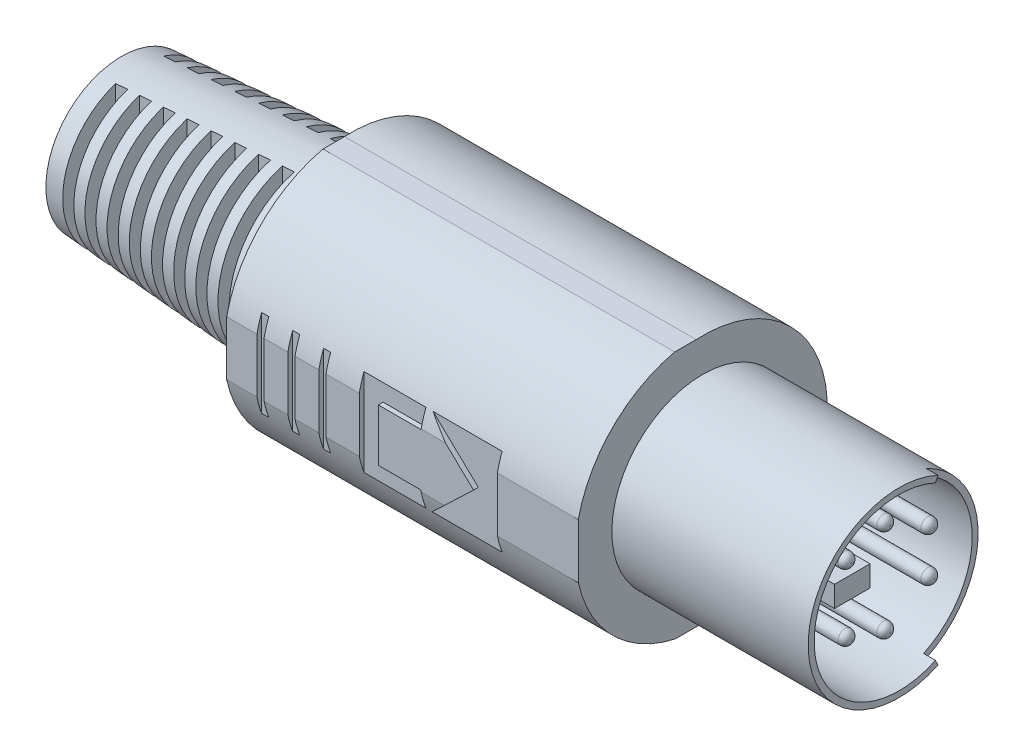
from build123d import *

# Parameters (mm, degrees)
SKETCH2_R                = 2.4384
BOSS_EXTRUDE_CABLE_DEPTH = 0.127
SKETCH13_R               = 4.87045
SKETCH12_R               = 4.03225
BODY_DEPTH               = 23.3299
SKETCH21_W               = 0.635
SKETCH21_H               = 5.3721
RIGID_CUTS_DEPTH         = 7.6421
RIGID_CUTS_DEPTH_BACK    = 7.6421
SKETCH16_R               = 4.8514
BOSS_EXTRUDE10_DEPTH     = 5.9
SKETCH17_R               = 4.5339
CUT_EXTRUDE4_DEPTH       = 0.8509
SKETCH18_R               = 4.5339
SKETCH18_R_2             = 0.381
SKETCH18_W               = 0.762
SKETCH18_H               = 2.1463
CUT_EXTRUDE5_DEPTH       = 12.7
SKETCH28_W               = 7.366
SKETCH28_H               = 6.858
SKETCH28_W_2             = 0.381
CUT_EXTRUDE7_DEPTH       = 0.254
SKETCH30_R               = 2.4384
SKETCH31_W               = 239.674694706
SKETCH31_H               = 23.82872503
CUT_EXTRUDE8_DEPTH       = 14.2842
FILLET1_R                = 0.3429
CUT_EXTRUDE9_DEPTH       = 0.635
SKETCH37_R               = 4.8514
CUT_EXTRUDE10_DEPTH      = 4.572
SKETCH39_R               = 16.8
SKETCH39_R_2             = 6.8
CUT_EXTRUDE_THIN1_DEPTH  = 19
SKETCH40_W               = 0.762
SKETCH40_H               = 2.1463
CUT_EXTRUDE11_DEPTH      = 12.7
SKETCH41_R               = 0.381
CUT_EXTRUDE12_DEPTH      = 13.5509
SKETCH42_W               = 1.897262774
SKETCH42_H               = 1.120293518
BOSS_EXTRUDE11_DEPTH     = 12


with BuildPart() as part:
    # Sketch2 → Boss-Extrude cable (new body, symmetric)
    with BuildSketch(Plane(origin=(0, 0, 0), x_dir=(0, 0, -1), z_dir=(1, 0, 0))):
        Circle(SKETCH2_R)
    extrude(amount=BOSS_EXTRUDE_CABLE_DEPTH, both=True)

    # Sketch13 → Rigid Back section 0
    with BuildSketch(Plane(origin=(12.3825, 0, 0), x_dir=(0, 0, -1), z_dir=(1, 0, 0))):
        Circle(SKETCH13_R)
    # Sketch12 → Rigid Back section 1
    with BuildSketch(Plane(origin=(0.127, 0, 0), x_dir=(0, 0, -1), z_dir=(1, 0, 0))):
        Circle(SKETCH12_R)
    loft()

    # Sketch14 → Body (add)
    with BuildSketch(Plane(origin=(12.3825, 0, 0), x_dir=(0, 0, -1), z_dir=(1, 0, 0))):
        with BuildLine():
            Line((-0.35513361, 6.632599229), (-6.6421, 6.632599229))
            Line((-6.6421, 6.632599229), (-6.6421, -6.639769092))
            Line((-6.6421, -6.639769092), (-0.175951184, -6.639769092))
            ThreePointArc((-0.175951184, -6.639769092), (6.641494785, 0.089662909), (-0.35513361, 6.632599229))
        make_face()
    extrude(amount=BODY_DEPTH)

    # Sketch21 → Rigid Cuts (cut, two sides)
    with BuildSketch(Plane(origin=(0, 0, 0), x_dir=(1, 0, 0), z_dir=(0, 1, 0))) as rigid_cuts_sk:
        with Locations((10.299061765, 3.95605)):
            Rectangle(SKETCH21_W, SKETCH21_H)
        with Locations((10.299061765, -3.95605)):
            Rectangle(SKETCH21_W, SKETCH21_H)
        with Locations((9.029061765, 3.95605)):
            Rectangle(SKETCH21_W, SKETCH21_H)
        with Locations((9.029061765, -3.95605)):
            Rectangle(SKETCH21_W, SKETCH21_H)
        with Locations((7.759061765, 3.95605)):
            Rectangle(SKETCH21_W, SKETCH21_H)
        with Locations((7.759061765, -3.95605)):
            Rectangle(SKETCH21_W, SKETCH21_H)
        with Locations((6.489061765, 3.95605)):
            Rectangle(SKETCH21_W, SKETCH21_H)
        with Locations((6.489061765, -3.95605)):
            Rectangle(SKETCH21_W, SKETCH21_H)
        with Locations((5.219061765, 3.95605)):
            Rectangle(SKETCH21_W, SKETCH21_H)
        with Locations((5.219061765, -3.95605)):
            Rectangle(SKETCH21_W, SKETCH21_H)
        with Locations((3.949061765, 3.95605)):
            Rectangle(SKETCH21_W, SKETCH21_H)
        with Locations((3.949061765, -3.95605)):
            Rectangle(SKETCH21_W, SKETCH21_H)
        with Locations((2.679061765, 3.95605)):
            Rectangle(SKETCH21_W, SKETCH21_H)
        with Locations((2.679061765, -3.95605)):
            Rectangle(SKETCH21_W, SKETCH21_H)
        with Locations((1.409061765, 3.95605)):
            Rectangle(SKETCH21_W, SKETCH21_H)
        with Locations((1.409061765, -3.95605)):
            Rectangle(SKETCH21_W, SKETCH21_H)
    extrude(amount=RIGID_CUTS_DEPTH, mode=Mode.SUBTRACT)
    extrude(rigid_cuts_sk.sketch, amount=-RIGID_CUTS_DEPTH_BACK, mode=Mode.SUBTRACT)

    # Sketch16 → Boss-Extrude10 (add)
    with BuildSketch(Plane(origin=(35.7124, 0, 0), x_dir=(0, 0, -1), z_dir=(1, 0, 0))):
        Circle(SKETCH16_R)
    extrude(amount=BOSS_EXTRUDE10_DEPTH)

    # Sketch17 → Cut-Extrude4 (cut)
    with BuildSketch(Plane(origin=(41.6124, 0, 0), x_dir=(0, 0, -1), z_dir=(1, 0, 0))):
        Circle(SKETCH17_R)
    extrude(amount=-CUT_EXTRUDE4_DEPTH, mode=Mode.SUBTRACT)

    # Sketch18 → Cut-Extrude5 (cut)
    with BuildSketch(Plane(origin=(40.7615, 0, 0), x_dir=(0, 0, -1), z_dir=(1, 0, 0))):
        Circle(SKETCH18_R)
        with Locations((-1.68365116, -1.778)):
            Circle(SKETCH18_R_2, mode=Mode.SUBTRACT)
        with Locations((0.381, -2.476694855)):
            Circle(SKETCH18_R_2, mode=Mode.SUBTRACT)
        with Locations((2.730485233, -1.174742616)):
            Circle(SKETCH18_R_2, mode=Mode.SUBTRACT)
        with Locations((-1.68365116, 0)):
            Circle(SKETCH18_R_2, mode=Mode.SUBTRACT)
        with Locations((-1.68365116, 1.778)):
            Circle(SKETCH18_R_2, mode=Mode.SUBTRACT)
        with Locations((0.381, 0)):
            Rectangle(SKETCH18_W, SKETCH18_H, mode=Mode.SUBTRACT)
        with Locations((2.730485233, 1.174742616)):
            Circle(SKETCH18_R_2, mode=Mode.SUBTRACT)
        with Locations((0.381, 2.476694855)):
            Circle(SKETCH18_R_2, mode=Mode.SUBTRACT)
    extrude(amount=-CUT_EXTRUDE5_DEPTH, mode=Mode.SUBTRACT)

    # Sketch28 → Cut-Extrude7 (cut)
    with BuildSketch(Plane.XY.offset(6.6421)):
        with Locations((23.1394, 0.028599229)):
            Rectangle(SKETCH28_W, SKETCH28_H)
        Polygon((20.4724, 1.425599229), (20.4724, -1.368400771), (22.7584, -1.368400771), (22.7584, -2.638400771), (25.5524, 0.028599229), (22.7584, 2.695599229), (22.7584, 1.425599229), align=None, mode=Mode.SUBTRACT)
        with Locations((17.4879, 0.028599229)):
            Rectangle(SKETCH28_W_2, SKETCH28_H)
        with Locations((15.8369, 0.028599229)):
            Rectangle(SKETCH28_W_2, SKETCH28_H)
        with Locations((14.1859, 0.028599229)):
            Rectangle(SKETCH28_W_2, SKETCH28_H)
    extrude(amount=-CUT_EXTRUDE7_DEPTH, mode=Mode.SUBTRACT)

    # Sweep1: sweep along a path in PATH
    with BuildLine(Plane.XY) as sweep1_path:
        Line((0, 0), (-228.6, 0))
    # Sketch30 → Sweep1 (sweep)
    with BuildSketch(Plane.ZY.offset(0.127)):
        Circle(SKETCH30_R)
    sweep(path=sweep1_path.line)

    # Sketch31 → Cut-Extrude8 (cut, through all)
    with BuildSketch(Plane.XY.offset(6.6421)):
        with Locations((-119.710347353, -7.882112515)):
            Rectangle(SKETCH31_W, SKETCH31_H)
    extrude(amount=-CUT_EXTRUDE8_DEPTH, mode=Mode.SUBTRACT)

    # Fillet1
    fillet1_edges = [part.edges().sort_by_distance(p)[0] for p in [
        (40.7615, 1.174742616, -2.349485233),
        (40.7615, 2.476694855, 0),
        (40.7615, 1.778, 2.06465116),
        (40.7615, 0, 2.06465116),
        (40.7615, -2.476694855, 0),
        (40.7615, -1.174742616, -2.349485233),
        (40.7615, -1.778, 2.06465116),
    ]]
    fillet(fillet1_edges, radius=FILLET1_R)

    # Sketch36 → Cut-Extrude9 (cut)
    with BuildSketch(Plane(origin=(41.6124, 0, 0), x_dir=(0, 0, -1), z_dir=(1, 0, 0))):
        with BuildLine():
            Line((2.076319556, -4.384629866), (1.940434768, -4.09767765))
            ThreePointArc((1.940434768, -4.09767765), (4.533899988, -0.00032584), (1.941023728, 4.097398699))
            Line((1.941023728, 4.097398699), (2.076949759, 4.384331381))
            ThreePointArc((2.076949759, 4.384331381), (4.851399987, -0.000348658), (2.076319556, -4.384629866))
        make_face()
    extrude(amount=-CUT_EXTRUDE9_DEPTH, mode=Mode.SUBTRACT)

    # Sketch37 → Cut-Extrude10 (cut)
    with BuildSketch(Plane(origin=(35.7124, 0, 0), x_dir=(0, 0, -1), z_dir=(1, 0, 0))):
        with BuildLine():
            Line((-6.6421, -6.639769092), (-0.175951184, -6.639769092))
            ThreePointArc((-0.175951184, -6.639769092), (6.641494785, 0.089662909), (-0.35513361, 6.632599229))
            Line((-0.35513361, 6.632599229), (-6.6421, 6.632599229))
            Line((-6.6421, 6.632599229), (-6.6421, -6.639769092))
        make_face()
        Circle(SKETCH37_R, mode=Mode.SUBTRACT)
    extrude(amount=-CUT_EXTRUDE10_DEPTH, mode=Mode.SUBTRACT)

    # Sketch39 → Cut-Extrude-Thin1 (cut)
    with BuildSketch(Plane(origin=(31.1404, 0, 0), x_dir=(0, 0, -1), z_dir=(1, 0, 0))):
        Circle(SKETCH39_R)
        Circle(SKETCH39_R_2, mode=Mode.SUBTRACT)
    extrude(amount=-CUT_EXTRUDE_THIN1_DEPTH, mode=Mode.SUBTRACT)

    # Sketch40 → Cut-Extrude11 (cut)
    with BuildSketch(Plane(origin=(40.7615, 0, 0), x_dir=(0, 0, -1), z_dir=(1, 0, 0))):
        with Locations((0.381, 0)):
            Rectangle(SKETCH40_W, SKETCH40_H)
    extrude(amount=-CUT_EXTRUDE11_DEPTH, mode=Mode.SUBTRACT)

    # Sketch41 → Cut-Extrude12 (cut)
    with BuildSketch(Plane(origin=(41.6124, 0, 0), x_dir=(0, 0, -1), z_dir=(1, 0, 0))):
        with Locations((-1.68365116, 0)):
            Circle(SKETCH41_R)
    extrude(amount=-CUT_EXTRUDE12_DEPTH, mode=Mode.SUBTRACT)

    # Sketch42 → Boss-Extrude11 (add)
    with BuildSketch(Plane(origin=(28.0615, 0, 0), x_dir=(0, 0, -1), z_dir=(1, 0, 0))):
        with Locations((-0.948631387, 0)):
            Rectangle(SKETCH42_W, SKETCH42_H)
    extrude(amount=BOSS_EXTRUDE11_DEPTH)


solid = part.part
